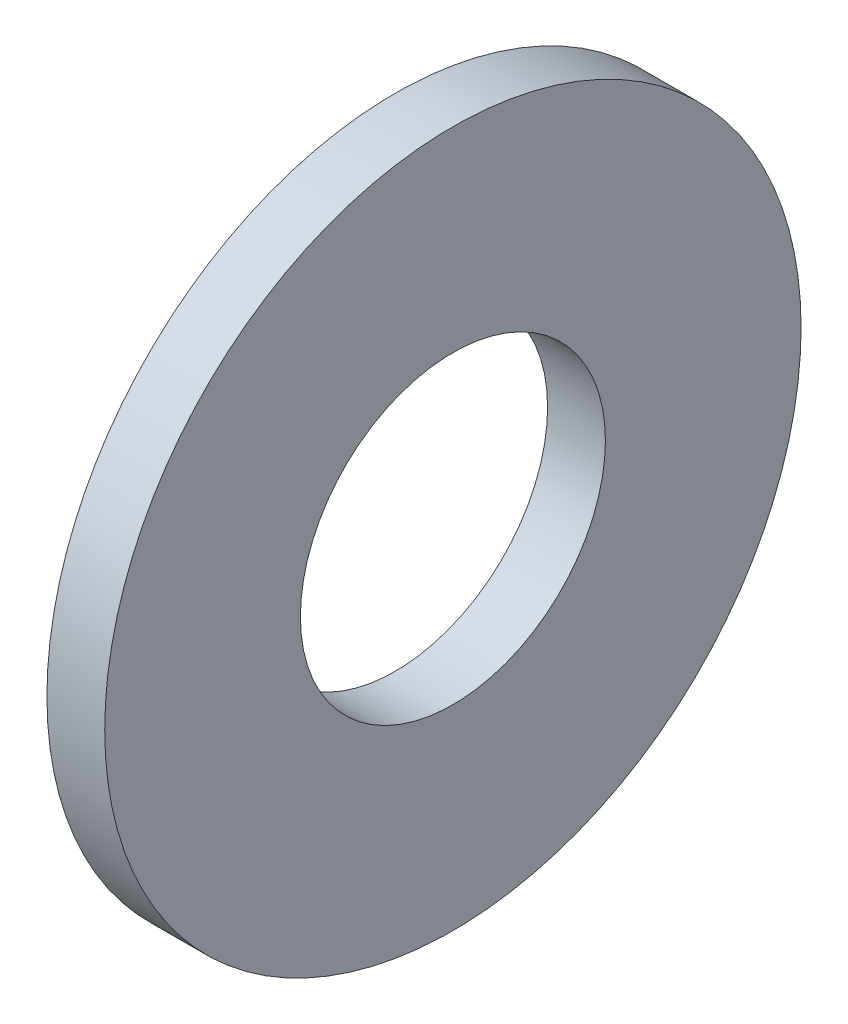
from build123d import *

# Parameters (mm, degrees)
SKETCH1_W = 2.1082
SKETCH1_H = 7.1374


with BuildPart() as part:
    # Sketch1 → Revolve1 (revolve)
    with BuildSketch(Plane.XY):
        with Locations((-1.0541, 9.1313)):
            Rectangle(SKETCH1_W, SKETCH1_H)
    revolve(axis=Axis((-34.925, 0, 0), (1, 0, 0)))


solid = part.part
